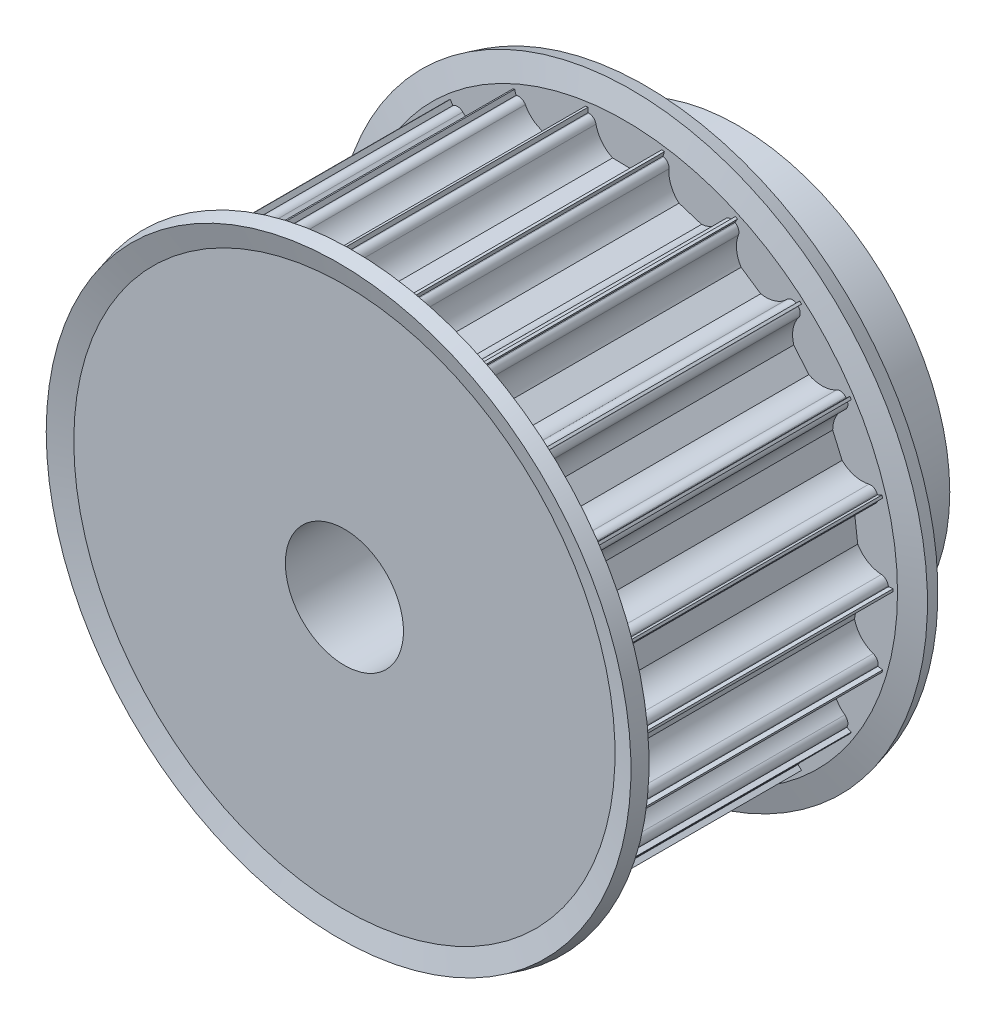
from build123d import *

# Parameters (mm, degrees)
CUT_EXTRUDE1_DEPTH = 41
CIRPATTERN1_COUNT  = 22


with BuildPart() as part:
    # Sketch2 → Revolve1 (revolve)
    with BuildSketch(Plane(origin=(0, 0, 0), x_dir=(0, 0, -1), z_dir=(1, 0, 0))):
        Polygon((0, 6), (0, 27.25), (30, 27.25), (30, 21.5), (40, 21.5), (40, 6), align=None)
    revolve(axis=Axis((0, 0, -88.99), (0, 0, 1)))

    # Sketch3 → Cut-Extrude1 (cut, through all)
    with BuildSketch(Plane.XY):
        with BuildLine():
            Line((3.674234614, 26.5), (3.75, 26.5))
            Line((3.75, 26.5), (3.75, 28.5))
            Line((3.75, 28.5), (-3.75, 28.5))
            Line((-3.75, 28.5), (-3.75, 26.5))
            Line((-3.75, 26.5), (-3.674234614, 26.5))
            ThreePointArc((-3.674234614, 26.5), (-3.199892965, 26.330947502), (-2.939387691, 25.9))
            ThreePointArc((-2.939387691, 25.9), (-2.350351386, 24.635637277), (-1.253227383, 23.774303552))
            Line((-1.253227383, 23.774303552), (1.144217343, 23.726776844))
            ThreePointArc((1.144217343, 23.726776844), (2.31293801, 24.589419523), (2.939387691, 25.9))
            ThreePointArc((2.939387691, 25.9), (3.199892965, 26.330947502), (3.674234614, 26.5))
        make_face()
    cut_extrude1 = extrude(amount=-CUT_EXTRUDE1_DEPTH, mode=Mode.SUBTRACT)

    # CirPattern1: Cut-Extrude1 ×22 about axis
    cirpattern1_axis = Axis((0, 0, 0), (0, 0, 1))
    for i in range(1, CIRPATTERN1_COUNT):
        add(cut_extrude1.rotate(cirpattern1_axis, i * 360 / CIRPATTERN1_COUNT), mode=Mode.SUBTRACT)

    # Sketch4 → Revolve2 (revolve)
    with BuildSketch(Plane(origin=(0, 0, 0), x_dir=(0, 0, -1), z_dir=(1, 0, 0))):
        Polygon((0, 22.690739153), (1.5, 22.690739153), (1.5, 27.690739153), (0.856921938, 30.090739153), (-0.591966801, 29.702510585), (0, 27.493260406), align=None)
        Polygon((29.143078062, 30.090739153), (30.591966801, 29.702510585), (30, 27.493260406), (30, 22.690739153), (28.5, 22.690739153), (28.5, 27.690739153), align=None)
    revolve(axis=Axis((0, 0, -88.99), (0, 0, 1)))


solid = part.part
